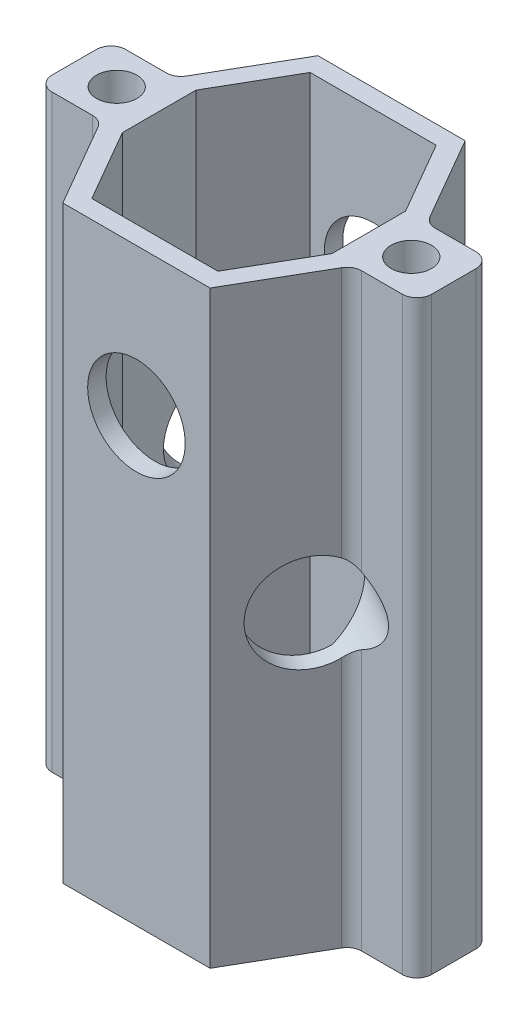
from build123d import *

# Parameters (mm, degrees)
BOSS_EXTRUDE1_DEPTH      = 101.6
FILLET1_R                = 2.54
SKETCH11_R               = 8.41375
CUT_EXTRUDE8_DEPTH       = 1
CUT_EXTRUDE8_DEPTH_BACK  = 44.994090512
SKETCH12_R               = 8.41375
CUT_EXTRUDE9_DEPTH       = 18.348522628
CUT_EXTRUDE9_DEPTH_BACK  = 62.34261314
SKETCH13_R               = 8.41375
CUT_EXTRUDE10_DEPTH      = 18.348522628
CUT_EXTRUDE10_DEPTH_BACK = 62.34261314


with BuildPart() as part:
    # Sketch2 → Boss-Extrude1 (new body)
    with BuildSketch(Plane(origin=(0, 0, 0), x_dir=(1, 0, 0), z_dir=(0, 1, 0))):
        with BuildLine():
            Line((-23.65375, 3.024593723), (-21.733825791, 6.35))
            Line((-21.733825791, 6.35), (-32.732348419, 6.35))
            Line((-32.732348419, 6.35), (-32.732348419, -6.35))
            Line((-32.732348419, -6.35), (-21.733825791, -6.35))
            Line((-21.733825791, -6.35), (-23.65375, -3.024593723))
            ThreePointArc((-23.65375, -3.024593723), (-28.8925, 0), (-23.65375, 3.024593723))
        make_face()
        with BuildLine():
            Line((32.732348419, 6.35), (21.733825791, 6.35))
            Line((21.733825791, 6.35), (23.65375, 3.024593723))
            ThreePointArc((23.65375, 3.024593723), (27.14625, 3.024593723), (28.8925, 0))
            ThreePointArc((28.8925, 0), (27.14625, -3.024593723), (23.65375, -3.024593723))
            Line((23.65375, -3.024593723), (21.733825791, -6.35))
            Line((21.733825791, -6.35), (32.732348419, -6.35))
            Line((32.732348419, -6.35), (32.732348419, 6.35))
        make_face()
        Polygon((12.7, 21.997045256), (-12.7, 21.997045256), (-21.733825791, 6.35), (-18.067651581, 6.35), (-10.866912895, 18.822045256), (10.866912895, 18.822045256), (18.067651581, 6.35), (21.733825791, 6.35), align=None)
        Polygon((-10.866912895, -18.822045256), (-18.067651581, -6.35), (-21.733825791, -6.35), (-12.7, -21.997045256), (12.7, -21.997045256), (21.733825791, -6.35), (18.067651581, -6.35), (10.866912895, -18.822045256), align=None)
        with BuildLine():
            Line((-18.067651581, 6.35), (-21.733825791, 6.35))
            Line((-21.733825791, 6.35), (-23.65375, 3.024593723))
            ThreePointArc((-23.65375, 3.024593723), (-22.375406277, 1.74625), (-21.9075, 0))
            ThreePointArc((-21.9075, 0), (-22.375406277, -1.74625), (-23.65375, -3.024593723))
            Line((-23.65375, -3.024593723), (-21.733825791, -6.35))
            Line((-21.733825791, -6.35), (-18.067651581, -6.35))
            Line((-18.067651581, -6.35), (-21.733825791, 0))
            Line((-21.733825791, 0), (-18.067651581, 6.35))
        make_face()
        Polygon((-18.067651581, -6.35), (-18.067651581, 6.35), (-21.733825791, 0), align=None)
        with BuildLine():
            Line((23.65375, 3.024593723), (21.733825791, 6.35))
            Line((21.733825791, 6.35), (18.067651581, 6.35))
            Line((18.067651581, 6.35), (21.733825791, 0))
            Line((21.733825791, 0), (18.067651581, -6.35))
            Line((18.067651581, -6.35), (21.733825791, -6.35))
            Line((21.733825791, -6.35), (23.65375, -3.024593723))
            ThreePointArc((23.65375, -3.024593723), (21.9075, 0), (23.65375, 3.024593723))
        make_face()
        Polygon((21.733825791, 0), (18.067651581, 6.35), (18.067651581, -6.35), align=None)
    extrude(amount=BOSS_EXTRUDE1_DEPTH)

    # Fillet1
    fillet1_edges = [part.edges().sort_by_distance(p)[0] for p in [
        (21.733825791, 50.8, -6.35),
        (32.732348419, 50.8, -6.35),
        (32.732348419, 50.8, 6.35),
        (21.733825791, 50.8, 6.35),
        (-21.733825791, 50.8, 6.35),
        (-32.732348419, 50.8, 6.35),
        (-32.732348419, 50.8, -6.35),
        (-21.733825791, 50.8, -6.35),
    ]]
    fillet(fillet1_edges, radius=FILLET1_R)

    # Sketch11 → Cut-Extrude8 (cut, two sides)
    with BuildSketch(Plane(origin=(0, 0, -21.997045256), x_dir=(-1, 0, 0), z_dir=(0, 0, -1))) as cut_extrude8_sk:
        with Locations((0, 76.2)):
            Circle(SKETCH11_R)
    extrude(amount=CUT_EXTRUDE8_DEPTH, mode=Mode.SUBTRACT)
    extrude(cut_extrude8_sk.sketch, amount=-CUT_EXTRUDE8_DEPTH_BACK, mode=Mode.SUBTRACT)

    # Sketch12 → Cut-Extrude9 (cut, two sides)
    with BuildSketch(Plane(origin=(-19.05, 0, -10.998522628), x_dir=(-0.5, 0, 0.866025404), z_dir=(-0.866025404, 0, -0.5))) as cut_extrude9_sk:
        with Locations((0, 50.8)):
            Circle(SKETCH12_R)
    extrude(amount=CUT_EXTRUDE9_DEPTH, mode=Mode.SUBTRACT)
    extrude(cut_extrude9_sk.sketch, amount=-CUT_EXTRUDE9_DEPTH_BACK, mode=Mode.SUBTRACT)

    # Sketch13 → Cut-Extrude10 (cut, two sides)
    with BuildSketch(Plane(origin=(19.05, 0, -10.998522628), x_dir=(-0.5, 0, -0.866025404), z_dir=(0.866025404, 0, -0.5))) as cut_extrude10_sk:
        with Locations((0, 25.4)):
            Circle(SKETCH13_R)
    extrude(amount=CUT_EXTRUDE10_DEPTH, mode=Mode.SUBTRACT)
    extrude(cut_extrude10_sk.sketch, amount=-CUT_EXTRUDE10_DEPTH_BACK, mode=Mode.SUBTRACT)


solid = part.part
